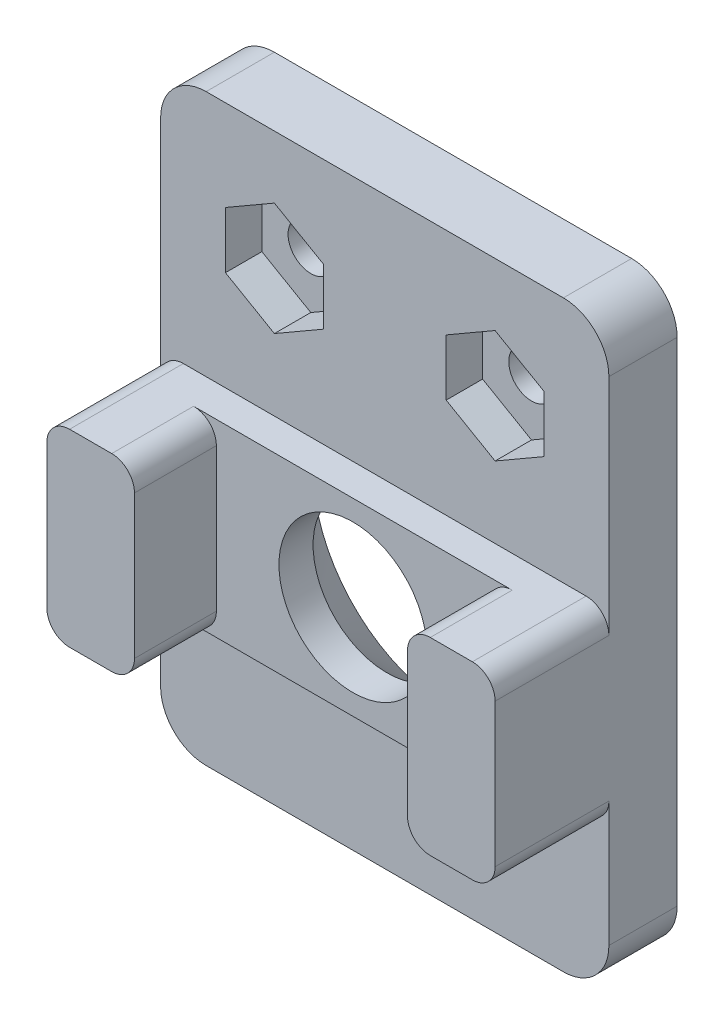
from build123d import *

# Parameters (mm, degrees)
SKETCH_1_W          = 19.7
SKETCH_1_H          = 25.65
SKETCH_1_R          = 3.25
SKETCH_1_R_2        = 1
EXTRUDE_1_DEPTH     = 3
SKETCH_1_3_W        = 3.85
SKETCH_1_3_H        = 8.3
EXTRUDE_2_DEPTH     = 8
FILLET_1_R          = 2
CHAMFER_1_SIZE      = 2.9
FILLET_2_R          = 1
EXTRUDE_START       = 3
EXTRUDE_4_DEPTH     = 1.4
FILLET_3_R          = 1
CUT_EXTRUDE_START   = 1.4
SKETCH_1_5_R        = 1
CUT_EXTRUDE_1_DEPTH = 1.6


with BuildPart() as part:
    # Эскиз1 → Бобышка-Вытянуть1 (new body)
    with BuildSketch(Plane.XY):
        with Locations((8.965987089, 2.175)):
            Rectangle(SKETCH_1_W, SKETCH_1_H)
        with Locations((8.965987089, 0)):
            Circle(SKETCH_1_R, mode=Mode.SUBTRACT)
        with Locations((4.115987089, 9.774393406)):
            Circle(SKETCH_1_R_2, mode=Mode.SUBTRACT)
        with Locations((13.815987089, 9.774393406)):
            Circle(SKETCH_1_R_2, mode=Mode.SUBTRACT)
    extrude(amount=EXTRUDE_1_DEPTH)

    # Эскиз1<3> → Бобышка-Вытянуть2 (add)
    with BuildSketch(Plane.XY):
        with Locations((1.040987089, 0)):
            Rectangle(SKETCH_1_3_W, SKETCH_1_3_H)
        with Locations((16.890987089, 0)):
            Rectangle(SKETCH_1_3_W, SKETCH_1_3_H)
    extrude(amount=EXTRUDE_2_DEPTH)

    # Скругление1
    fillet_1_edges = [part.edges().sort_by_distance(p)[0] for p in [
        (-0.884012911, -10.65, 1.5),
        (-0.884012911, 15, 1.5),
        (18.815987089, 15, 1.5),
        (18.815987089, -10.65, 1.5),
    ]]
    fillet(fillet_1_edges, radius=FILLET_1_R)

    # Фаска1
    chamfer_1_edges = [part.edges().sort_by_distance(p)[0] for p in [
        (5.715987089, 0, 0),
    ]]
    chamfer(chamfer_1_edges, length=CHAMFER_1_SIZE)

    # Скругление2
    fillet_2_edges = [part.edges().sort_by_distance(p)[0] for p in [
        (-0.884012911, 4.15, 5.5),
        (-0.884012911, -4.15, 5.5),
        (18.815987089, -4.15, 5.5),
        (18.815987089, 4.15, 5.5),
    ]]
    fillet(fillet_2_edges, radius=FILLET_2_R)

    # Эскиз1<4> → Бобышка-Вытянуть4 (add)
    with BuildSketch(Plane.XY.offset(EXTRUDE_START)):
        with BuildLine():
            Line((2.965987089, 0), (2.965987089, -4.15))
            Line((2.965987089, -4.15), (14.965987089, -4.15))
            Line((14.965987089, -4.15), (14.965987089, 0))
            Line((14.965987089, 0), (12.215987089, 0))
            ThreePointArc((12.215987089, 0), (8.965987089, -3.25), (5.715987089, 0))
            Line((5.715987089, 0), (2.965987089, 0))
        make_face()
        with BuildLine():
            Line((14.965987089, 4.15), (2.965987089, 4.15))
            Line((2.965987089, 4.15), (2.965987089, 0))
            Line((2.965987089, 0), (5.715987089, 0))
            ThreePointArc((5.715987089, 0), (8.965987089, 3.25), (12.215987089, 0))
            Line((12.215987089, 0), (14.965987089, 0))
            Line((14.965987089, 0), (14.965987089, 4.15))
        make_face()
    extrude(amount=EXTRUDE_4_DEPTH)

    # Скругление3
    fillet_3_edges = [part.edges().sort_by_distance(p)[0] for p in [
        (2.965987089, -4.15, 6.2),
        (2.965987089, 4.15, 6.2),
        (14.965987089, -4.15, 6.2),
        (14.965987089, 4.15, 6.2),
    ]]
    fillet(fillet_3_edges, radius=FILLET_3_R)

    # Эскиз1<5> → Вырез-Вытянуть1 (cut)
    with BuildSketch(Plane.XY.offset(CUT_EXTRUDE_START)):
        Polygon((6.265987089, 8.533090327), (6.265987089, 11.015696485), (4.115987089, 12.256999563), (1.965987089, 11.015696485), (1.965987089, 8.533090327), (4.115987089, 7.291787248), align=None)
        with Locations((4.115987089, 9.774393406)):
            Circle(SKETCH_1_5_R, mode=Mode.SUBTRACT)
        Polygon((15.965987089, 8.533090327), (15.965987089, 11.015696485), (13.815987089, 12.256999563), (11.665987089, 11.015696485), (11.665987089, 8.533090327), (13.815987089, 7.291787248), align=None)
        with Locations((13.815987089, 9.774393406)):
            Circle(SKETCH_1_5_R, mode=Mode.SUBTRACT)
    extrude(amount=CUT_EXTRUDE_1_DEPTH, mode=Mode.SUBTRACT)


solid = part.part
